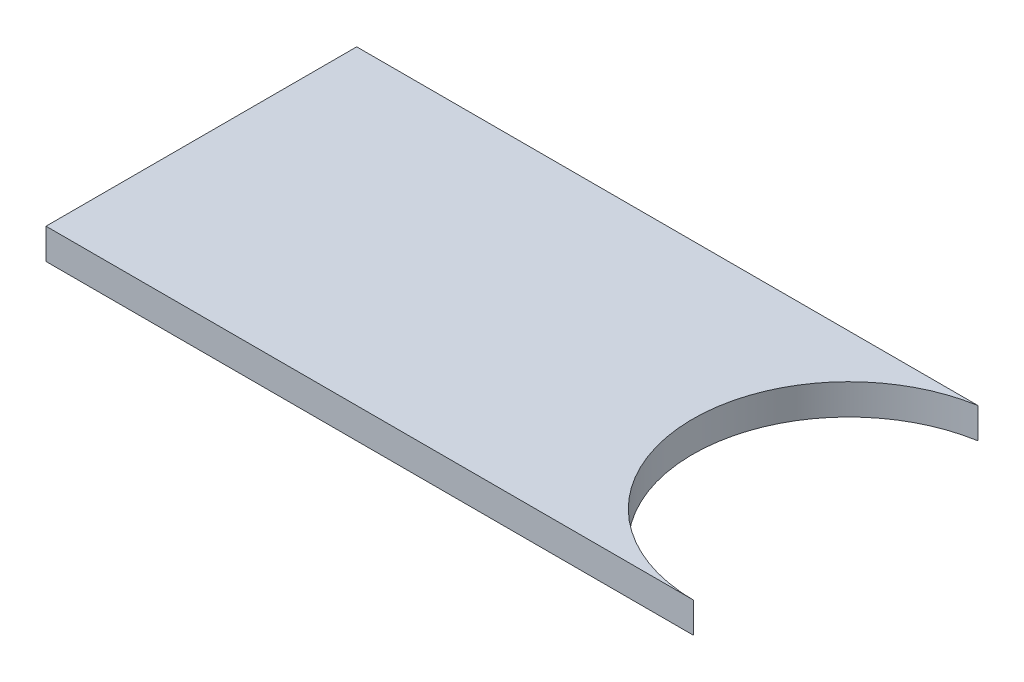
from build123d import *

# Parameters (mm, degrees)
BOSS_EXTRUDE1_DEPTH = 6


with BuildPart() as part:
    # Sketch1 → Boss-Extrude1 (new body)
    with BuildSketch(Plane(origin=(0, 0, 0), x_dir=(1, 0, 0), z_dir=(0, 1, 0))):
        with BuildLine():
            Line((0, 0), (0, 60.96))
            Line((0, 60.96), (121.908718719, 60.96))
            add(Edge.make_bspline(
                [(121.908718719, 60.96), (93.964633175, 56.213826392), (96.30731907, 28.163886845), (98.650004964, 0.113947297), (127, 0)],
                knots=[4.884225241, 4.884225241, 4.884225241, 6.368279473, 6.368279473, 7.852333705, 7.852333705, 7.852333705], degree=2, weights=[1, 0.737100182, 1, 0.737100182, 1]))
            Line((127, 0), (0, 0))
        make_face()
    extrude(amount=BOSS_EXTRUDE1_DEPTH)


solid = part.part
